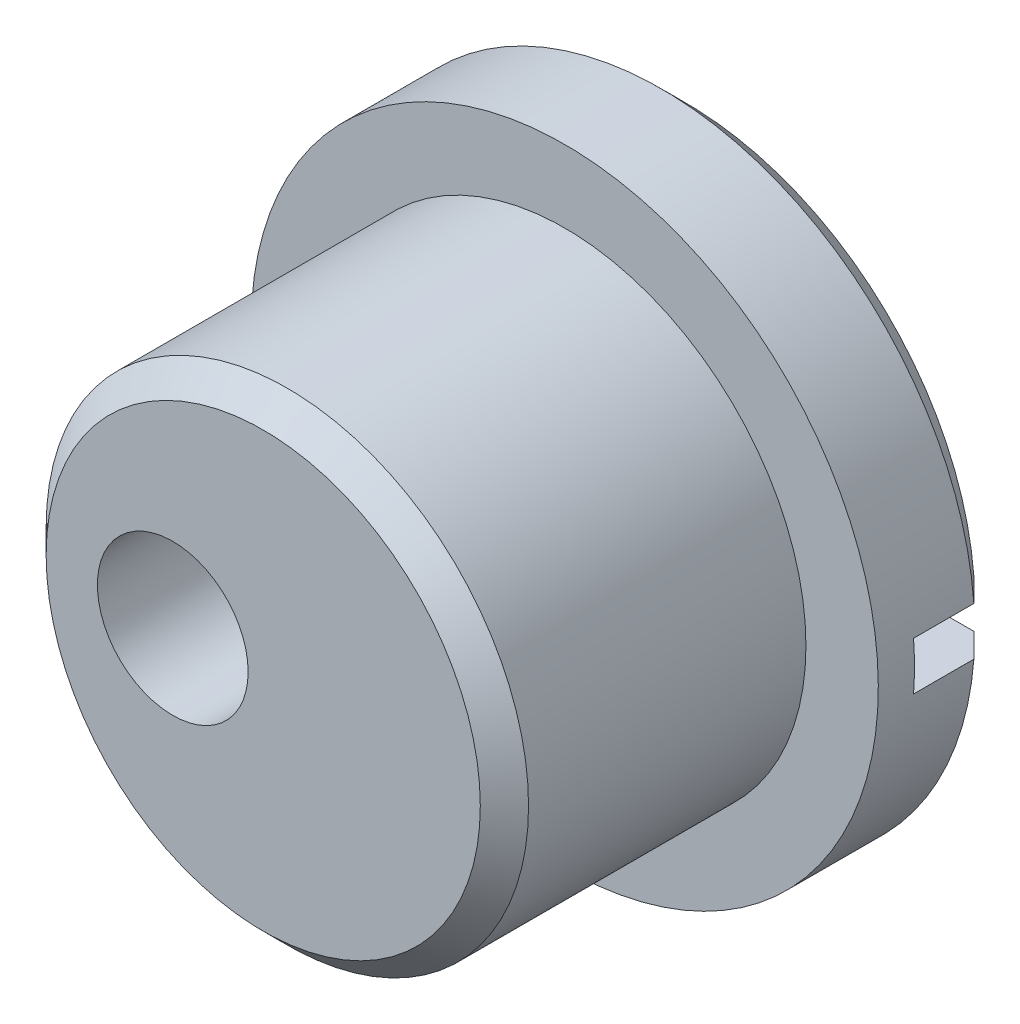
from build123d import *

# Parameters (mm, degrees)
SKETCH1_R           = 4
BOSS_EXTRUDE1_DEPTH = 5
SKETCH2_R           = 5.2
BOSS_EXTRUDE2_DEPTH = 2
SKETCH3_R           = 1.25
CUT_EXTRUDE2_DEPTH  = 8
CHAMFER1_SIZE       = 0.4
SKETCH4_W           = 20
SKETCH4_H           = 0.8
CUT_EXTRUDE3_DEPTH  = 1.4
SKETCH5_R           = 2
CUT_EXTRUDE4_DEPTH  = 2.5
FILLET1_R           = 0.5


with BuildPart() as part:
    # Sketch1 → Boss-Extrude1 (new body)
    with BuildSketch(Plane.XY):
        with Locations((1.5, 95.99791663)):
            Circle(SKETCH1_R)
    extrude(amount=BOSS_EXTRUDE1_DEPTH)

    # Sketch2 → Boss-Extrude2 (add)
    with BuildSketch(Plane(origin=(0, 0, 0), x_dir=(-1, 0, 0), z_dir=(0, 0, -1))):
        with Locations((-1.5, 95.99791663)):
            Circle(SKETCH2_R)
    extrude(amount=BOSS_EXTRUDE2_DEPTH)

    # Sketch3 → Cut-Extrude2 (cut, through all)
    with BuildSketch(Plane.XY.offset(5)):
        with Locations((0, 95.99791663)):
            Circle(SKETCH3_R)
    extrude(amount=-CUT_EXTRUDE2_DEPTH, mode=Mode.SUBTRACT)

    # Chamfer1
    chamfer1_edges = [part.edges().sort_by_distance(p)[0] for p in [
        (-2.5, 95.99791663, 5),
        (6.7, 95.99791663, -2),
    ]]
    chamfer(chamfer1_edges, length=CHAMFER1_SIZE)

    # Sketch4 → Cut-Extrude3 (cut)
    with BuildSketch(Plane(origin=(0, 0, -2), x_dir=(-1, 0, 0), z_dir=(0, 0, -1))):
        with Locations((-1.5, 95.99791663)):
            Rectangle(SKETCH4_W, SKETCH4_H)
    extrude(amount=-CUT_EXTRUDE3_DEPTH, mode=Mode.SUBTRACT)

    # Sketch5 → Cut-Extrude4 (cut)
    with BuildSketch(Plane(origin=(0, 0, -2), x_dir=(-1, 0, 0), z_dir=(0, 0, -1))):
        with Locations((0, 95.99791663)):
            Circle(SKETCH5_R)
    extrude(amount=-CUT_EXTRUDE4_DEPTH, mode=Mode.SUBTRACT)

    # Fillet1
    fillet1_edges = [part.edges().sort_by_distance(p)[0] for p in [
        (2, 95.99791663, 0.5),
    ]]
    fillet(fillet1_edges, radius=FILLET1_R)


solid = part.part
